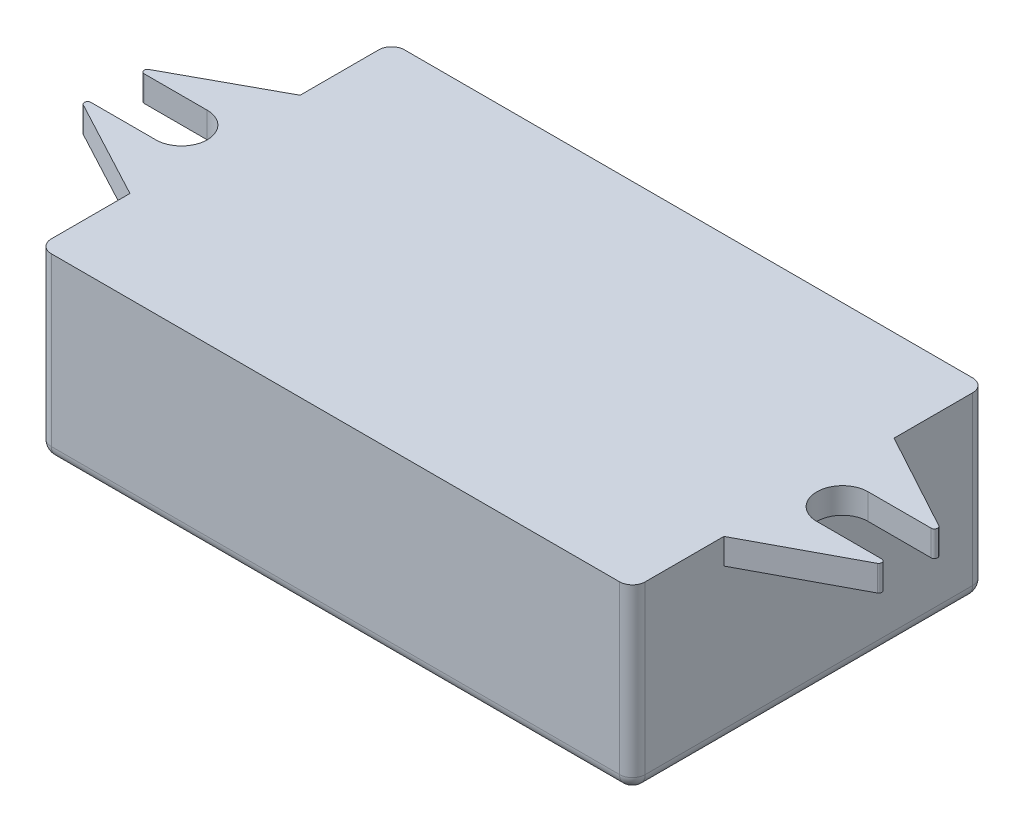
from build123d import *

# Parameters (mm, degrees)
BOSS_EXTRUDE3_DEPTH = 2
SKETCH4_W           = 46.25
SKETCH4_H           = 27.5
BOSS_EXTRUDE4_DEPTH = 12
FILLET1_R           = 1
FILLET2_R           = 1
FILLET3_R           = 0.25


with BuildPart() as part:
    # Sketch1 → Boss-Extrude3 (new body)
    with BuildSketch(Plane(origin=(0, 0, 0), x_dir=(1, 0, 0), z_dir=(0, 1, 0))):
        with BuildLine():
            Line((33.003141421, 5.895474545), (41.503141421, 1.270474545))
            Line((41.503141421, 1.270474545), (35.611544818, 1.270474545))
            ThreePointArc((35.611544818, 1.270474545), (33.611544818, -0.729525455), (35.611544818, -2.729525455))
            Line((35.611544818, -2.729525455), (41.672555807, -2.729525455))
            Line((41.672555807, -2.729525455), (33.003141421, -7.354525455))
            Line((33.003141421, -7.354525455), (33.003141421, -14.479525455))
            Line((33.003141421, -14.479525455), (-13.246858579, -14.479525455))
            Line((-13.246858579, -14.479525455), (-13.246858579, -7.354525455))
            Line((-13.246858579, -7.354525455), (-21.916272965, -2.729525455))
            Line((-21.916272965, -2.729525455), (-15.855261975, -2.729525455))
            ThreePointArc((-15.855261975, -2.729525455), (-13.855261975, -0.729525455), (-15.855261975, 1.270474545))
            Line((-15.855261975, 1.270474545), (-21.746858579, 1.270474545))
            Line((-21.746858579, 1.270474545), (-13.246858579, 5.895474545))
            Line((-13.246858579, 5.895474545), (-13.246858579, 13.020474545))
            Line((-13.246858579, 13.020474545), (33.003141421, 13.020474545))
            Line((33.003141421, 13.020474545), (33.003141421, 5.895474545))
        make_face()
    extrude(amount=BOSS_EXTRUDE3_DEPTH)

    # Sketch4 → Boss-Extrude4 (add)
    with BuildSketch(Plane.XZ):
        with Locations((9.878141421, 0.729525455)):
            Rectangle(SKETCH4_W, SKETCH4_H)
    extrude(amount=BOSS_EXTRUDE4_DEPTH)

    # Fillet1
    fillet1_edges = [part.edges().sort_by_distance(p)[0] for p in [
        (9.878141421, -12, 14.479525455),
    ]]
    fillet(fillet1_edges, radius=FILLET1_R)

    # Fillet2
    fillet2_edges = [part.edges().sort_by_distance(p)[0] for p in [
        (-13.246858579, -4.5, 14.479525455),
        (33.003141421, -4.5, 14.479525455),
        (33.003141421, -5, -13.020474545),
        (-13.246858579, -5, -13.020474545),
        (9.878141421, -12, -13.020474545),
        (33.003141421, -12, 0.229525455),
        (-13.246858579, -12, 0.229525455),
        (-13.246858579, -11.707106781, 14.186632236),
        (33.003141421, -11.707106781, 14.186632236),
    ]]
    fillet(fillet2_edges, radius=FILLET2_R)

    # Fillet3
    fillet3_edges = [part.edges().sort_by_distance(p)[0] for p in [
        (-21.746858579, 1, -1.270474545),
        (-21.916272965, 1, 2.729525455),
        (41.672555807, 1, 2.729525455),
        (41.503141421, 1, -1.270474545),
    ]]
    fillet(fillet3_edges, radius=FILLET3_R)


solid = part.part
